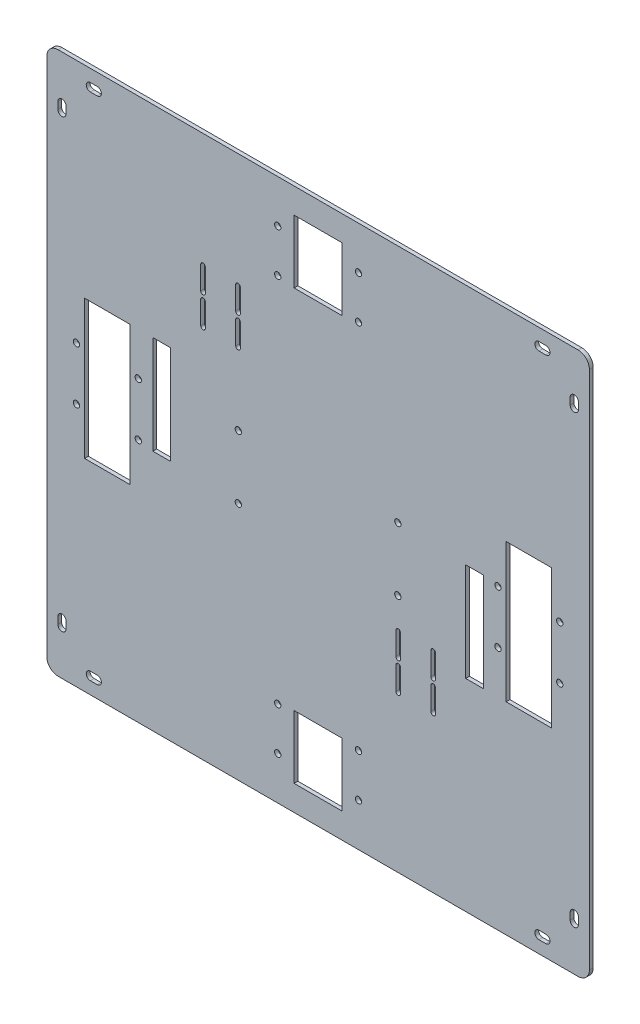
from build123d import *

# Parameters (mm, degrees)
SKETCH1_W           = 430
SKETCH1_H           = 430
BOSS_EXTRUDE1_DEPTH = 3
CUT_EXTRUDE5_REACH  = 5
SKETCH7_W           = 36
SKETCH7_H           = 110
CUT_EXTRUDE6_DEPTH  = 4
SKETCH9_W           = 38
SKETCH9_H           = 50
CUT_EXTRUDE7_DEPTH  = 4
SKETCH10_R          = 2.5
CUT_EXTRUDE8_DEPTH  = 4
SKETCH14_W          = 14
SKETCH14_H          = 78
CUT_EXTRUDE11_DEPTH = 4
CUT_EXTRUDE12_DEPTH = 4
FILLET1_R           = 9
SKETCH17_R          = 2.5
CUT_EXTRUDE13_DEPTH = 4
SKETCH18_R          = 2.5
CUT_EXTRUDE14_DEPTH = 4


with BuildPart() as part:
    # Sketch1 → Boss-Extrude1 (new body)
    with BuildSketch(Plane.XY):
        with Locations((0, 30.651830075)):
            Rectangle(SKETCH1_W, SKETCH1_H)
    extrude(amount=BOSS_EXTRUDE1_DEPTH)

    # Sketch6 → Cut-Extrude5 (cut, up to next)
    with BuildSketch(Plane.XY.offset(3), mode=Mode.PRIVATE) as cut_extrude5_sk1:
        with BuildLine():
            Line((-199.75, 204.651830161), (-199.75, 210.151830161))
            ThreePointArc((-199.75, 210.151830161), (-203, 213.401830161), (-206.25, 210.151830161))
            Line((-206.25, 210.151830161), (-206.25, 204.651830161))
            ThreePointArc((-206.25, 204.651830161), (-203, 201.401830161), (-199.75, 204.651830161))
        make_face()
    cut_extrude5_tool1 = extrude(cut_extrude5_sk1.sketch, amount=-CUT_EXTRUDE5_REACH, mode=Mode.PRIVATE) & part.part
    add(cut_extrude5_tool1.solids().sort_by_distance((-203, 207.40183, 3))[0], mode=Mode.SUBTRACT)
    # Sketch6 → Cut-Extrude5 (cut, up to next)
    with BuildSketch(Plane.XY.offset(3), mode=Mode.PRIVATE) as cut_extrude5_sk2:
        with BuildLine():
            Line((-180.5, 229.401830161), (-175, 229.401830161))
            ThreePointArc((-175, 229.401830161), (-171.75, 232.651830161), (-175, 235.901830161))
            Line((-175, 235.901830161), (-180.5, 235.901830161))
            ThreePointArc((-180.5, 235.901830161), (-183.75, 232.651830161), (-180.5, 229.401830161))
        make_face()
    cut_extrude5_tool2 = extrude(cut_extrude5_sk2.sketch, amount=-CUT_EXTRUDE5_REACH, mode=Mode.PRIVATE) & part.part
    add(cut_extrude5_tool2.solids().sort_by_distance((-177.75, 232.65183, 3))[0], mode=Mode.SUBTRACT)
    # Sketch6 → Cut-Extrude5 (cut, up to next)
    with BuildSketch(Plane.XY.offset(3), mode=Mode.PRIVATE) as cut_extrude5_sk3:
        with BuildLine():
            Line((-175, -174.598169839), (-180.5, -174.598169839))
            ThreePointArc((-180.5, -174.598169839), (-183.75, -171.348169839), (-180.5, -168.098169839))
            Line((-180.5, -168.098169839), (-175, -168.098169839))
            ThreePointArc((-175, -168.098169839), (-171.75, -171.348169839), (-175, -174.598169839))
        make_face()
    cut_extrude5_tool3 = extrude(cut_extrude5_sk3.sketch, amount=-CUT_EXTRUDE5_REACH, mode=Mode.PRIVATE) & part.part
    add(cut_extrude5_tool3.solids().sort_by_distance((-177.75, -171.34817, 3))[0], mode=Mode.SUBTRACT)
    # Sketch6 → Cut-Extrude5 (cut, up to next)
    with BuildSketch(Plane.XY.offset(3), mode=Mode.PRIVATE) as cut_extrude5_sk4:
        with BuildLine():
            Line((-206.25, -148.848169839), (-206.25, -143.348169839))
            ThreePointArc((-206.25, -143.348169839), (-203, -140.098169839), (-199.75, -143.348169839))
            Line((-199.75, -143.348169839), (-199.75, -148.848169839))
            ThreePointArc((-199.75, -148.848169839), (-203, -152.098169839), (-206.25, -148.848169839))
        make_face()
    cut_extrude5_tool4 = extrude(cut_extrude5_sk4.sketch, amount=-CUT_EXTRUDE5_REACH, mode=Mode.PRIVATE) & part.part
    add(cut_extrude5_tool4.solids().sort_by_distance((-203, -146.09817, 3))[0], mode=Mode.SUBTRACT)
    # Sketch6 → Cut-Extrude5 (cut, up to next)
    with BuildSketch(Plane.XY.offset(3), mode=Mode.PRIVATE) as cut_extrude5_sk5:
        with BuildLine():
            Line((199.75, -143.348169839), (199.75, -148.848169839))
            ThreePointArc((199.75, -148.848169839), (203, -152.098169839), (206.25, -148.848169839))
            Line((206.25, -148.848169839), (206.25, -143.348169839))
            ThreePointArc((206.25, -143.348169839), (203, -140.098169839), (199.75, -143.348169839))
        make_face()
    cut_extrude5_tool5 = extrude(cut_extrude5_sk5.sketch, amount=-CUT_EXTRUDE5_REACH, mode=Mode.PRIVATE) & part.part
    add(cut_extrude5_tool5.solids().sort_by_distance((203, -146.09817, 3))[0], mode=Mode.SUBTRACT)
    # Sketch6 → Cut-Extrude5 (cut, up to next)
    with BuildSketch(Plane.XY.offset(3), mode=Mode.PRIVATE) as cut_extrude5_sk6:
        with BuildLine():
            Line((180.5, -168.098169839), (175, -168.098169839))
            ThreePointArc((175, -168.098169839), (171.75, -171.348169839), (175, -174.598169839))
            Line((175, -174.598169839), (180.5, -174.598169839))
            ThreePointArc((180.5, -174.598169839), (183.75, -171.348169839), (180.5, -168.098169839))
        make_face()
    cut_extrude5_tool6 = extrude(cut_extrude5_sk6.sketch, amount=-CUT_EXTRUDE5_REACH, mode=Mode.PRIVATE) & part.part
    add(cut_extrude5_tool6.solids().sort_by_distance((177.75, -171.34817, 3))[0], mode=Mode.SUBTRACT)
    # Sketch6 → Cut-Extrude5 (cut, up to next)
    with BuildSketch(Plane.XY.offset(3), mode=Mode.PRIVATE) as cut_extrude5_sk7:
        with BuildLine():
            Line((175, 235.901830161), (180.5, 235.901830161))
            ThreePointArc((180.5, 235.901830161), (183.75, 232.651830161), (180.5, 229.401830161))
            Line((180.5, 229.401830161), (175, 229.401830161))
            ThreePointArc((175, 229.401830161), (171.75, 232.651830161), (175, 235.901830161))
        make_face()
    cut_extrude5_tool7 = extrude(cut_extrude5_sk7.sketch, amount=-CUT_EXTRUDE5_REACH, mode=Mode.PRIVATE) & part.part
    add(cut_extrude5_tool7.solids().sort_by_distance((177.75, 232.65183, 3))[0], mode=Mode.SUBTRACT)
    # Sketch6 → Cut-Extrude5 (cut, up to next)
    with BuildSketch(Plane.XY.offset(3), mode=Mode.PRIVATE) as cut_extrude5_sk8:
        with BuildLine():
            Line((206.25, 210.151830161), (206.25, 204.651830161))
            ThreePointArc((206.25, 204.651830161), (203, 201.401830161), (199.75, 204.651830161))
            Line((199.75, 204.651830161), (199.75, 210.151830161))
            ThreePointArc((199.75, 210.151830161), (203, 213.401830161), (206.25, 210.151830161))
        make_face()
    cut_extrude5_tool8 = extrude(cut_extrude5_sk8.sketch, amount=-CUT_EXTRUDE5_REACH, mode=Mode.PRIVATE) & part.part
    add(cut_extrude5_tool8.solids().sort_by_distance((203, 207.40183, 3))[0], mode=Mode.SUBTRACT)

    # Sketch7 → Cut-Extrude6 (cut, through all)
    with BuildSketch(Plane(origin=(0, 0, 0), x_dir=(-1, 0, 0), z_dir=(0, 0, -1))):
        with Locations((167, 30.651830075)):
            Rectangle(SKETCH7_W, SKETCH7_H)
        with Locations((-167, 30.651830075)):
            Rectangle(SKETCH7_W, SKETCH7_H)
    extrude(amount=-CUT_EXTRUDE6_DEPTH, mode=Mode.SUBTRACT)

    # Sketch9 → Cut-Extrude7 (cut, through all)
    with BuildSketch(Plane(origin=(0, 0, 0), x_dir=(-1, 0, 0), z_dir=(0, 0, -1))):
        with Locations((0, -139.348169925)):
            Rectangle(SKETCH9_W, SKETCH9_H)
        with Locations((0, 200.651830075)):
            Rectangle(SKETCH9_W, SKETCH9_H)
    extrude(amount=-CUT_EXTRUDE7_DEPTH, mode=Mode.SUBTRACT)

    # Sketch10 → Cut-Extrude8 (cut, through all)
    with BuildSketch(Plane(origin=(0, 0, 0), x_dir=(-1, 0, 0), z_dir=(0, 0, -1))):
        with Locations((32, -150.348169925)):
            Circle(SKETCH10_R)
        with Locations((32, -116.348169925)):
            Circle(SKETCH10_R)
        with Locations((-32, -116.348169925)):
            Circle(SKETCH10_R)
        with Locations((-32, -150.348169925)):
            Circle(SKETCH10_R)
        with Locations((-32, 211.651830075)):
            Circle(SKETCH10_R)
        with Locations((-32, 177.651830075)):
            Circle(SKETCH10_R)
        with Locations((32, 177.651830075)):
            Circle(SKETCH10_R)
        with Locations((32, 211.651830075)):
            Circle(SKETCH10_R)
    extrude(amount=-CUT_EXTRUDE8_DEPTH, mode=Mode.SUBTRACT)

    # Sketch14 → Cut-Extrude11 (cut, through all)
    with BuildSketch(Plane(origin=(0, 0, 0), x_dir=(-1, 0, 0), z_dir=(0, 0, -1))):
        with Locations((124, 46.651830075)):
            Rectangle(SKETCH14_W, SKETCH14_H)
        with Locations((-124, 14.651830075)):
            Rectangle(SKETCH14_W, SKETCH14_H)
    extrude(amount=-CUT_EXTRUDE11_DEPTH, mode=Mode.SUBTRACT)

    # Sketch15 → Cut-Extrude12 (cut, through all)
    with BuildSketch(Plane(origin=(0, 0, 0), x_dir=(-1, 0, 0), z_dir=(0, 0, -1))):
        with BuildLine():
            ThreePointArc((-65.28, -53.893169925), (-63.455, -52.068169925), (-61.63, -53.893169925))
            Line((-61.63, -53.893169925), (-61.63, -48.693169925))
            ThreePointArc((-61.63, -48.693169925), (-63.455, -50.518169925), (-65.28, -48.693169925))
            Line((-65.28, -48.693169925), (-65.28, -53.893169925))
        make_face()
        with BuildLine():
            Line((-61.63, -60.893169925), (-61.63, -53.893169925))
            ThreePointArc((-61.63, -53.893169925), (-63.455, -55.718169925), (-65.28, -53.893169925))
            Line((-65.28, -53.893169925), (-65.28, -60.893169925))
            ThreePointArc((-65.28, -60.893169925), (-63.455, -62.718169925), (-61.63, -60.893169925))
        make_face()
        with BuildLine():
            ThreePointArc((-65.28, -53.893169925), (-63.455, -55.718169925), (-61.63, -53.893169925))
            ThreePointArc((-61.63, -53.893169925), (-63.455, -52.068169925), (-65.28, -53.893169925))
        make_face()
        with BuildLine():
            ThreePointArc((-65.28, -48.693169925), (-63.455, -46.868169925), (-61.63, -48.693169925))
            Line((-61.63, -48.693169925), (-61.63, -42.693169925))
            ThreePointArc((-61.63, -42.693169925), (-63.455, -40.868169925), (-65.28, -42.693169925))
            Line((-65.28, -42.693169925), (-65.28, -48.693169925))
        make_face()
        with BuildLine():
            ThreePointArc((-65.28, -48.693169925), (-63.455, -50.518169925), (-61.63, -48.693169925))
            ThreePointArc((-61.63, -48.693169925), (-63.455, -46.868169925), (-65.28, -48.693169925))
        make_face()
        with BuildLine():
            ThreePointArc((-65.28, -30.003169925), (-63.455, -28.178169925), (-61.63, -30.003169925))
            Line((-61.63, -30.003169925), (-61.63, -24.803169925))
            ThreePointArc((-61.63, -24.803169925), (-63.455, -26.628169925), (-65.28, -24.803169925))
            Line((-65.28, -24.803169925), (-65.28, -30.003169925))
        make_face()
        with BuildLine():
            Line((-61.63, -37.003169925), (-61.63, -30.003169925))
            ThreePointArc((-61.63, -30.003169925), (-63.455, -31.828169925), (-65.28, -30.003169925))
            Line((-65.28, -30.003169925), (-65.28, -37.003169925))
            ThreePointArc((-65.28, -37.003169925), (-63.455, -38.828169925), (-61.63, -37.003169925))
        make_face()
        with BuildLine():
            ThreePointArc((-65.28, -30.003169925), (-63.455, -31.828169925), (-61.63, -30.003169925))
            ThreePointArc((-61.63, -30.003169925), (-63.455, -28.178169925), (-65.28, -30.003169925))
        make_face()
        with BuildLine():
            ThreePointArc((-65.28, -24.803169925), (-63.455, -22.978169925), (-61.63, -24.803169925))
            Line((-61.63, -24.803169925), (-61.63, -18.803169925))
            ThreePointArc((-61.63, -18.803169925), (-63.455, -16.978169925), (-65.28, -18.803169925))
            Line((-65.28, -18.803169925), (-65.28, -24.803169925))
        make_face()
        with BuildLine():
            ThreePointArc((-65.28, -24.803169925), (-63.455, -26.628169925), (-61.63, -24.803169925))
            ThreePointArc((-61.63, -24.803169925), (-63.455, -22.978169925), (-65.28, -24.803169925))
        make_face()
        with BuildLine():
            ThreePointArc((-93.03, -53.893169925), (-91.205, -52.068169925), (-89.38, -53.893169925))
            Line((-89.38, -53.893169925), (-89.38, -48.693169925))
            ThreePointArc((-89.38, -48.693169925), (-91.205, -50.518169925), (-93.03, -48.693169925))
            Line((-93.03, -48.693169925), (-93.03, -53.893169925))
        make_face()
        with BuildLine():
            Line((-89.38, -60.893169925), (-89.38, -53.893169925))
            ThreePointArc((-89.38, -53.893169925), (-91.205, -55.718169925), (-93.03, -53.893169925))
            Line((-93.03, -53.893169925), (-93.03, -60.893169925))
            ThreePointArc((-93.03, -60.893169925), (-91.205, -62.718169925), (-89.38, -60.893169925))
        make_face()
        with BuildLine():
            ThreePointArc((-93.03, -53.893169925), (-91.205, -55.718169925), (-89.38, -53.893169925))
            ThreePointArc((-89.38, -53.893169925), (-91.205, -52.068169925), (-93.03, -53.893169925))
        make_face()
        with BuildLine():
            ThreePointArc((-93.03, -48.693169925), (-91.205, -46.868169925), (-89.38, -48.693169925))
            Line((-89.38, -48.693169925), (-89.38, -42.693169925))
            ThreePointArc((-89.38, -42.693169925), (-91.205, -40.868169925), (-93.03, -42.693169925))
            Line((-93.03, -42.693169925), (-93.03, -48.693169925))
        make_face()
        with BuildLine():
            ThreePointArc((-93.03, -48.693169925), (-91.205, -50.518169925), (-89.38, -48.693169925))
            ThreePointArc((-89.38, -48.693169925), (-91.205, -46.868169925), (-93.03, -48.693169925))
        make_face()
        with BuildLine():
            ThreePointArc((-93.03, -30.003169925), (-91.205, -28.178169925), (-89.38, -30.003169925))
            Line((-89.38, -30.003169925), (-89.38, -24.803169925))
            ThreePointArc((-89.38, -24.803169925), (-91.205, -26.628169925), (-93.03, -24.803169925))
            Line((-93.03, -24.803169925), (-93.03, -30.003169925))
        make_face()
        with BuildLine():
            Line((-89.38, -37.003169925), (-89.38, -30.003169925))
            ThreePointArc((-89.38, -30.003169925), (-91.205, -31.828169925), (-93.03, -30.003169925))
            Line((-93.03, -30.003169925), (-93.03, -37.003169925))
            ThreePointArc((-93.03, -37.003169925), (-91.205, -38.828169925), (-89.38, -37.003169925))
        make_face()
        with BuildLine():
            ThreePointArc((-93.03, -30.003169925), (-91.205, -31.828169925), (-89.38, -30.003169925))
            ThreePointArc((-89.38, -30.003169925), (-91.205, -28.178169925), (-93.03, -30.003169925))
        make_face()
        with BuildLine():
            ThreePointArc((-93.03, -24.803169925), (-91.205, -22.978169925), (-89.38, -24.803169925))
            Line((-89.38, -24.803169925), (-89.38, -18.803169925))
            ThreePointArc((-89.38, -18.803169925), (-91.205, -16.978169925), (-93.03, -18.803169925))
            Line((-93.03, -18.803169925), (-93.03, -24.803169925))
        make_face()
        with BuildLine():
            ThreePointArc((-93.03, -24.803169925), (-91.205, -26.628169925), (-89.38, -24.803169925))
            ThreePointArc((-89.38, -24.803169925), (-91.205, -22.978169925), (-93.03, -24.803169925))
        make_face()
        with BuildLine():
            ThreePointArc((89.38, 118.758660151), (91.205, 120.583660151), (93.03, 118.758660151))
            Line((93.03, 118.758660151), (93.03, 123.958660151))
            ThreePointArc((93.03, 123.958660151), (91.205, 122.133660151), (89.38, 123.958660151))
            Line((89.38, 123.958660151), (89.38, 118.758660151))
        make_face()
        with BuildLine():
            ThreePointArc((89.38, 118.758660151), (91.205, 116.933660151), (93.03, 118.758660151))
            ThreePointArc((93.03, 118.758660151), (91.205, 120.583660151), (89.38, 118.758660151))
        make_face()
        with BuildLine():
            Line((93.03, 112.758660151), (93.03, 118.758660151))
            ThreePointArc((93.03, 118.758660151), (91.205, 116.933660151), (89.38, 118.758660151))
            Line((89.38, 118.758660151), (89.38, 112.758660151))
            ThreePointArc((89.38, 112.758660151), (91.205, 110.933660151), (93.03, 112.758660151))
        make_face()
        with BuildLine():
            ThreePointArc((89.38, 123.958660151), (91.205, 125.783660151), (93.03, 123.958660151))
            Line((93.03, 123.958660151), (93.03, 130.958660151))
            ThreePointArc((93.03, 130.958660151), (91.205, 132.783660151), (89.38, 130.958660151))
            Line((89.38, 130.958660151), (89.38, 123.958660151))
        make_face()
        with BuildLine():
            ThreePointArc((89.38, 123.958660151), (91.205, 122.133660151), (93.03, 123.958660151))
            ThreePointArc((93.03, 123.958660151), (91.205, 125.783660151), (89.38, 123.958660151))
        make_face()
        with BuildLine():
            ThreePointArc((89.38, 142.648660151), (91.205, 144.473660151), (93.03, 142.648660151))
            Line((93.03, 142.648660151), (93.03, 147.848660151))
            ThreePointArc((93.03, 147.848660151), (91.205, 146.023660151), (89.38, 147.848660151))
            Line((89.38, 147.848660151), (89.38, 142.648660151))
        make_face()
        with BuildLine():
            ThreePointArc((89.38, 142.648660151), (91.205, 140.823660151), (93.03, 142.648660151))
            ThreePointArc((93.03, 142.648660151), (91.205, 144.473660151), (89.38, 142.648660151))
        make_face()
        with BuildLine():
            Line((93.03, 136.648660151), (93.03, 142.648660151))
            ThreePointArc((93.03, 142.648660151), (91.205, 140.823660151), (89.38, 142.648660151))
            Line((89.38, 142.648660151), (89.38, 136.648660151))
            ThreePointArc((89.38, 136.648660151), (91.205, 134.823660151), (93.03, 136.648660151))
        make_face()
        with BuildLine():
            ThreePointArc((89.38, 147.848660151), (91.205, 149.673660151), (93.03, 147.848660151))
            Line((93.03, 147.848660151), (93.03, 154.848660151))
            ThreePointArc((93.03, 154.848660151), (91.205, 156.673660151), (89.38, 154.848660151))
            Line((89.38, 154.848660151), (89.38, 147.848660151))
        make_face()
        with BuildLine():
            ThreePointArc((89.38, 147.848660151), (91.205, 146.023660151), (93.03, 147.848660151))
            ThreePointArc((93.03, 147.848660151), (91.205, 149.673660151), (89.38, 147.848660151))
        make_face()
        with BuildLine():
            ThreePointArc((61.63, 142.648660151), (63.455, 144.473660151), (65.28, 142.648660151))
            Line((65.28, 142.648660151), (65.28, 147.848660151))
            ThreePointArc((65.28, 147.848660151), (63.455, 146.023660151), (61.63, 147.848660151))
            Line((61.63, 147.848660151), (61.63, 142.648660151))
        make_face()
        with BuildLine():
            ThreePointArc((61.63, 142.648660151), (63.455, 140.823660151), (65.28, 142.648660151))
            ThreePointArc((65.28, 142.648660151), (63.455, 144.473660151), (61.63, 142.648660151))
        make_face()
        with BuildLine():
            Line((65.28, 136.648660151), (65.28, 142.648660151))
            ThreePointArc((65.28, 142.648660151), (63.455, 140.823660151), (61.63, 142.648660151))
            Line((61.63, 142.648660151), (61.63, 136.648660151))
            ThreePointArc((61.63, 136.648660151), (63.455, 134.823660151), (65.28, 136.648660151))
        make_face()
        with BuildLine():
            ThreePointArc((61.63, 147.848660151), (63.455, 149.673660151), (65.28, 147.848660151))
            Line((65.28, 147.848660151), (65.28, 154.848660151))
            ThreePointArc((65.28, 154.848660151), (63.455, 156.673660151), (61.63, 154.848660151))
            Line((61.63, 154.848660151), (61.63, 147.848660151))
        make_face()
        with BuildLine():
            ThreePointArc((61.63, 147.848660151), (63.455, 146.023660151), (65.28, 147.848660151))
            ThreePointArc((65.28, 147.848660151), (63.455, 149.673660151), (61.63, 147.848660151))
        make_face()
        with BuildLine():
            ThreePointArc((61.63, 118.758660151), (63.455, 120.583660151), (65.28, 118.758660151))
            Line((65.28, 118.758660151), (65.28, 123.958660151))
            ThreePointArc((65.28, 123.958660151), (63.455, 122.133660151), (61.63, 123.958660151))
            Line((61.63, 123.958660151), (61.63, 118.758660151))
        make_face()
        with BuildLine():
            ThreePointArc((61.63, 118.758660151), (63.455, 116.933660151), (65.28, 118.758660151))
            ThreePointArc((65.28, 118.758660151), (63.455, 120.583660151), (61.63, 118.758660151))
        make_face()
        with BuildLine():
            Line((65.28, 112.758660151), (65.28, 118.758660151))
            ThreePointArc((65.28, 118.758660151), (63.455, 116.933660151), (61.63, 118.758660151))
            Line((61.63, 118.758660151), (61.63, 112.758660151))
            ThreePointArc((61.63, 112.758660151), (63.455, 110.933660151), (65.28, 112.758660151))
        make_face()
        with BuildLine():
            ThreePointArc((61.63, 123.958660151), (63.455, 125.783660151), (65.28, 123.958660151))
            Line((65.28, 123.958660151), (65.28, 130.958660151))
            ThreePointArc((65.28, 130.958660151), (63.455, 132.783660151), (61.63, 130.958660151))
            Line((61.63, 130.958660151), (61.63, 123.958660151))
        make_face()
        with BuildLine():
            ThreePointArc((61.63, 123.958660151), (63.455, 122.133660151), (65.28, 123.958660151))
            ThreePointArc((65.28, 123.958660151), (63.455, 125.783660151), (61.63, 123.958660151))
        make_face()
    extrude(amount=-CUT_EXTRUDE12_DEPTH, mode=Mode.SUBTRACT)

    # Fillet1
    fillet1_edges = [part.edges().sort_by_distance(p)[0] for p in [
        (-215, 245.651830075, 1.5),
        (215, 245.651830075, 1.5),
        (215, -184.348169925, 1.5),
        (-215, -184.348169925, 1.5),
    ]]
    fillet(fillet1_edges, radius=FILLET1_R)

    # Sketch17 → Cut-Extrude13 (cut, through all)
    with BuildSketch(Plane(origin=(0, 0, 0), x_dir=(-1, 0, 0), z_dir=(0, 0, -1))):
        with Locations((191.5, 51.651830075)):
            Circle(SKETCH17_R)
        with Locations((191.5, 9.651830075)):
            Circle(SKETCH17_R)
        with Locations((142.5, 51.651830075)):
            Circle(SKETCH17_R)
        with Locations((142.5, 9.651830075)):
            Circle(SKETCH17_R)
        with Locations((-191.5, 51.651830075)):
            Circle(SKETCH17_R)
        with Locations((-191.5, 9.651830075)):
            Circle(SKETCH17_R)
        with Locations((-142.5, 9.651830075)):
            Circle(SKETCH17_R)
        with Locations((-142.5, 51.651830075)):
            Circle(SKETCH17_R)
    extrude(amount=-CUT_EXTRUDE13_DEPTH, mode=Mode.SUBTRACT)

    # Sketch18 → Cut-Extrude14 (cut, through all)
    with BuildSketch(Plane(origin=(0, 0, 0), x_dir=(-1, 0, 0), z_dir=(0, 0, -1))):
        with Locations((63.2, 55.651830161)):
            Circle(SKETCH18_R)
        with Locations((63.2, 5.651830161)):
            Circle(SKETCH18_R)
        with Locations((-63.2, 55.651830161)):
            Circle(SKETCH18_R)
        with Locations((-63.2, 5.651830161)):
            Circle(SKETCH18_R)
    extrude(amount=-CUT_EXTRUDE14_DEPTH, mode=Mode.SUBTRACT)


solid = part.part
